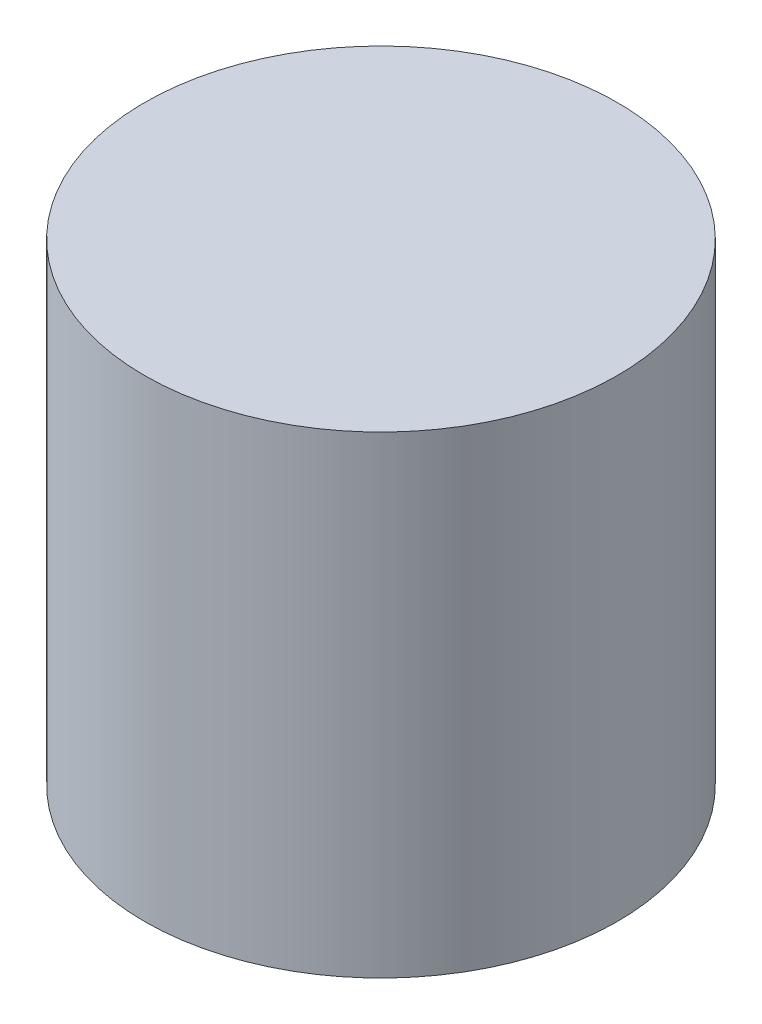
from build123d import *

# Parameters (mm, degrees)
SKETCH1_R           = 75
BOSS_EXTRUDE1_DEPTH = 150


with BuildPart() as part:
    # Sketch1 → Boss-Extrude1 (new body)
    with BuildSketch(Plane(origin=(0, -150, 0), x_dir=(1, 0, 0), z_dir=(0, 1, 0))):
        with Locations((250, 500)):
            Circle(SKETCH1_R)
    extrude(amount=BOSS_EXTRUDE1_DEPTH)


solid = part.part
